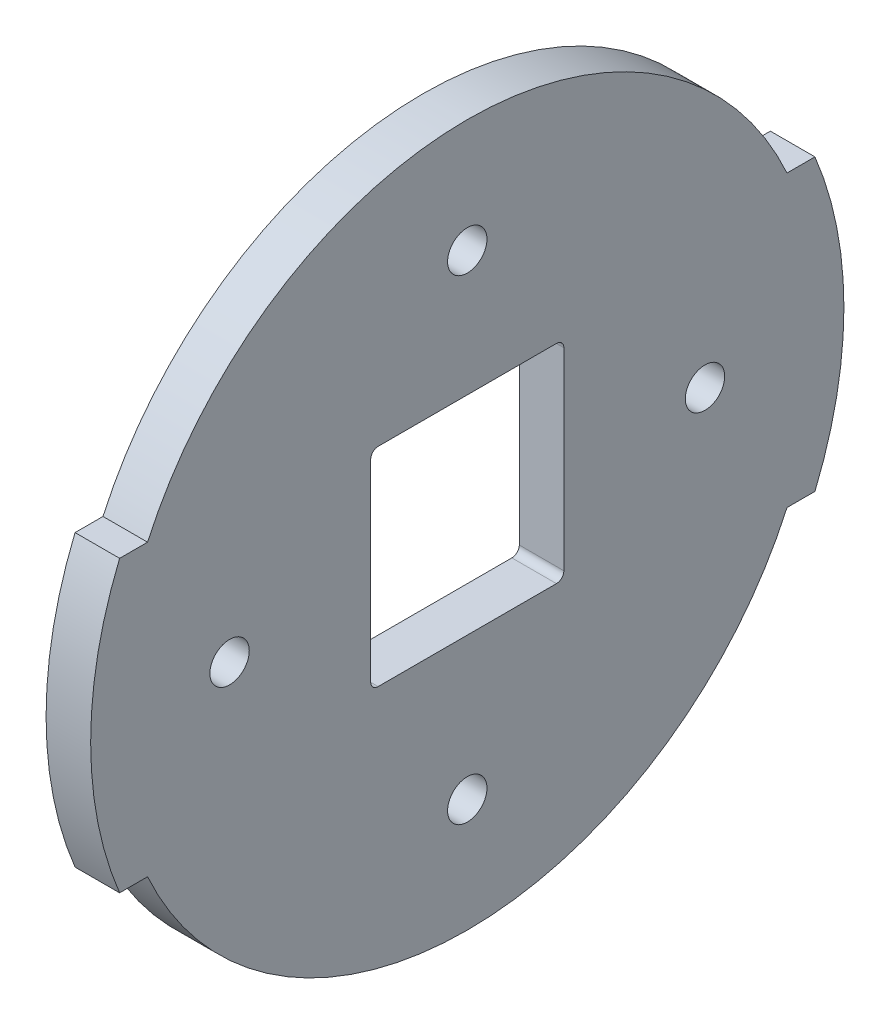
from build123d import *

# Parameters (mm, degrees)
BOSS_EXTRUDE1_DEPTH      = 6
CUT_EXTRUDE1_DEPTH       = 20
M5_CLEARANCE_HOLE1_D     = 5.3
M5_CLEARANCE_HOLE1_DEPTH = 15
M5_CLEARANCE_HOLE1_TIP   = 1.59228064


with BuildPart() as part:
    # Sketch1 → Boss-Extrude1 (new body)
    with BuildSketch(Plane(origin=(0, 0, 0), x_dir=(0, 0, -1), z_dir=(1, 0, 0))):
        with BuildLine():
            Line((-46.8, 19.5), (-43.038500206, 19.5))
            ThreePointArc((-43.038500206, 19.5), (0, 47.25), (43.038500206, 19.5))
            Line((43.038500206, 19.5), (46.8, 19.5))
            ThreePointArc((46.8, 19.5), (50.7, 0), (46.8, -19.5))
            Line((46.8, -19.5), (43.038500206, -19.5))
            ThreePointArc((43.038500206, -19.5), (0, -47.25), (-43.038500206, -19.5))
            Line((-43.038500206, -19.5), (-46.8, -19.5))
            ThreePointArc((-46.8, -19.5), (-50.7, 0), (-46.8, 19.5))
        make_face()
    extrude(amount=BOSS_EXTRUDE1_DEPTH)

    # Sketch2 → Cut-Extrude1 (cut)
    with BuildSketch(Plane(origin=(6, 0, 0), x_dir=(0, 0, -1), z_dir=(1, 0, 0))):
        with BuildLine():
            ThreePointArc((12, -11.85), (12.707106781, -11.557106781), (13, -10.85))
            Line((13, -10.85), (13, -3.85))
            Line((13, -3.85), (13, 14.15))
            ThreePointArc((13, 14.15), (12.707106781, 14.857106781), (12, 15.15))
            Line((12, 15.15), (-12, 15.15))
            ThreePointArc((-12, 15.15), (-12.707106781, 14.857106781), (-13, 14.15))
            Line((-13, 14.15), (-13, -3.85))
            Line((-13, -3.85), (-13, -10.85))
            ThreePointArc((-13, -10.85), (-12.707106781, -11.557106781), (-12, -11.85))
            Line((-12, -11.85), (12, -11.85))
        make_face()
        with BuildLine():
            Line((-12, -12.85), (12, -12.85))
            ThreePointArc((12, -12.85), (12.707106781, -12.557106781), (13, -11.85))
            Line((13, -11.85), (13, -10.85))
            ThreePointArc((13, -10.85), (12.707106781, -11.557106781), (12, -11.85))
            Line((12, -11.85), (-12, -11.85))
            ThreePointArc((-12, -11.85), (-12.707106781, -11.557106781), (-13, -10.85))
            Line((-13, -10.85), (-13, -11.85))
            ThreePointArc((-13, -11.85), (-12.707106781, -12.557106781), (-12, -12.85))
        make_face()
    extrude(amount=-CUT_EXTRUDE1_DEPTH, mode=Mode.SUBTRACT)

    # M5 Clearance Hole1
    with Locations(Plane.ZY):
        with Locations((-32, 0), (0, 32), (32, 0), (0, -32)):
            Hole(M5_CLEARANCE_HOLE1_D / 2, depth=M5_CLEARANCE_HOLE1_DEPTH)
            with Locations((0, 0, -(M5_CLEARANCE_HOLE1_DEPTH + M5_CLEARANCE_HOLE1_TIP / 2))):  # 118° drill point
                Cone(0, M5_CLEARANCE_HOLE1_D / 2, M5_CLEARANCE_HOLE1_TIP, mode=Mode.SUBTRACT)


solid = part.part
